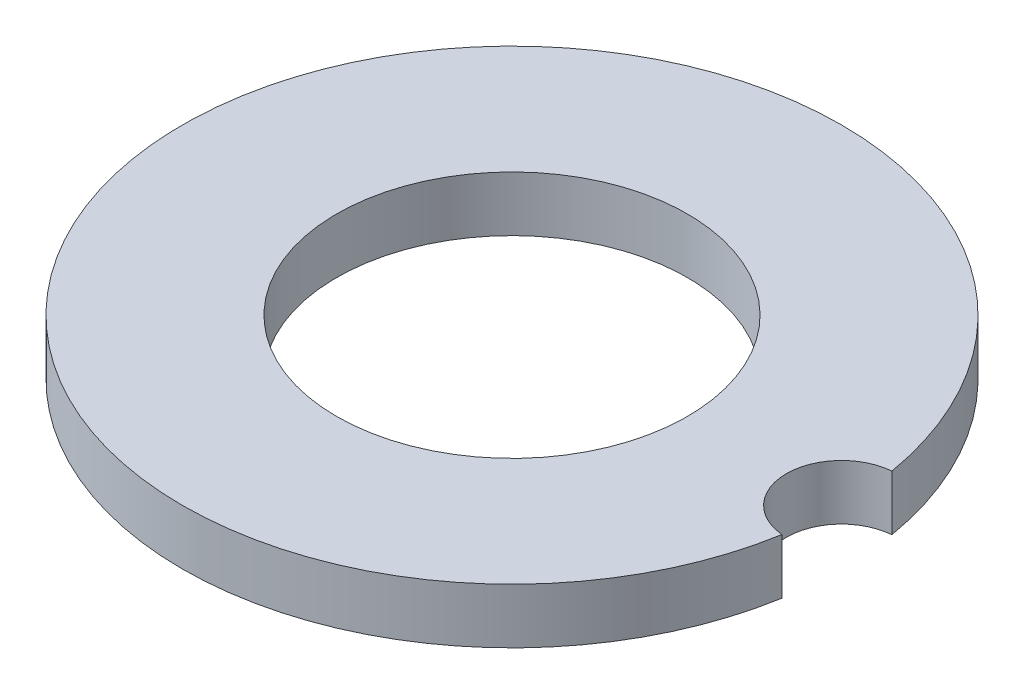
from build123d import *

# Parameters (mm, degrees)
SKETCH1_R           = 75.9206
BOSS_EXTRUDE1_DEPTH = 12.7
SKETCH1_10_R        = 40.4114
CUT_EXTRUDE2_DEPTH  = 109.116441898
CUT_EXTRUDE3_DEPTH  = 109.116441898


with BuildPart() as part:
    # Sketch1 → Boss-Extrude1 (new body)
    with BuildSketch(Plane(origin=(0, 0, 0), x_dir=(1, 0, 0), z_dir=(0, 1, 0))):
        Circle(SKETCH1_R)
    extrude(amount=BOSS_EXTRUDE1_DEPTH)

    # Sketch1_10 → Cut-Extrude2 (cut, through all)
    with BuildSketch(Plane(origin=(0, 0, 0), x_dir=(1, 0, 0), z_dir=(0, 1, 0))):
        Circle(SKETCH1_10_R)
    extrude(amount=CUT_EXTRUDE2_DEPTH, mode=Mode.SUBTRACT)

    # Sketch2 → Cut-Extrude3 (cut, through all)
    with BuildSketch(Plane(origin=(0, 12.7, 0), x_dir=(1, 0, 0), z_dir=(0, 1, 0))):
        with BuildLine():
            Line((76.2, 12.7), (76.2, -12.7))
            ThreePointArc((76.2, -12.7), (63.217526972, 0), (76.2, 12.7))
        make_face()
    extrude(amount=-CUT_EXTRUDE3_DEPTH, mode=Mode.SUBTRACT)


solid = part.part
